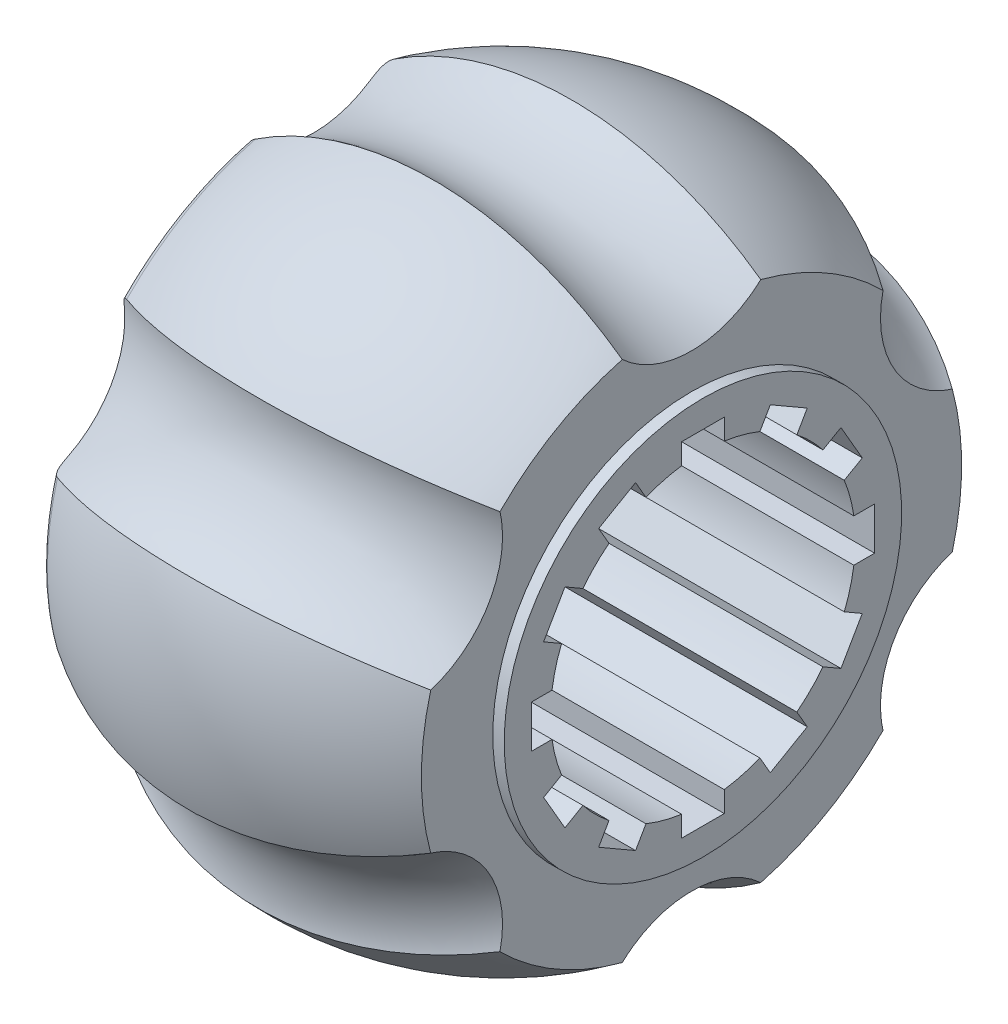
from build123d import *

# Parameters (mm, degrees)
FILLET1_R          = 2
SKETCH3_R          = 8.335
CIRPATTERN1_COUNT  = 6
CUT_EXTRUDE1_REACH = 69.845
SKETCH5_W          = 3.058833335
SKETCH5_H          = 3.5
CIRPATTERN2_COUNT  = 12


with BuildPart() as part:
    # Sketch1 → Revolve1 (revolve)
    with BuildSketch(Plane.XY):
        with BuildLine():
            Line((13.386210924, -10.675476076), (13.386210924, -4.817713103))
            ThreePointArc((13.386210924, -4.817713103), (-2.116785533, 0.057748096), (-17.613789076, -4.836728616))
            Line((-17.613789076, -4.836728616), (-17.613789076, -13.475476076))
            Line((-17.613789076, -13.475476076), (-16.613789076, -14.475476076))
            Line((-16.613789076, -14.475476076), (13.4271182, -14.475476076))
            Line((13.4271182, -14.475476076), (14.323961654, -14.475476076))
            Line((14.323961654, -14.475476076), (14.323961654, -10.675476076))
            Line((14.323961654, -10.675476076), (13.386210924, -10.675476076))
        make_face()
    revolve(axis=Axis((13.4271182, -26.975476076, 0), (-1, 0, 0)))

    # Fillet1
    fillet1_edges = [part.edges().sort_by_distance(p)[0] for p in [
        (-17.613789076, -49.114223536, 0),
    ]]
    fillet(fillet1_edges, radius=FILLET1_R)

    # Cut-Sweep2: sweep along a path in Sketch4
    with BuildLine(Plane.XY) as cut_sweep2_path:
        ThreePointArc((-17.613789076, -0.853454732), (2.484971781, 3.057963853), (20.501054004, -6.67240945))
    # Sketch3 → Cut-Sweep2 (sweep, cut)
    with BuildSketch(Plane.ZY.offset(17.613789076)):
        with Locations((0, 0.524523924)):
            Circle(SKETCH3_R)
    cut_sweep2 = sweep(path=cut_sweep2_path.line, mode=Mode.SUBTRACT)

    # CirPattern1: Cut-Sweep2 ×6 about axis
    cirpattern1_axis = Axis((-17.613789076, -26.975476076, 0), (1, 0, 0))
    for i in range(1, CIRPATTERN1_COUNT):
        add(cut_sweep2.rotate(cirpattern1_axis, i * 360 / CIRPATTERN1_COUNT), mode=Mode.SUBTRACT)

    # Sketch5 → Cut-Extrude1 (cut, up to next)
    with BuildSketch(Plane.ZY.offset(17.613789076), mode=Mode.PRIVATE) as cut_extrude1_sk1:
        with Locations((-12.55060814, -26.975476076)):
            Rectangle(SKETCH5_W, SKETCH5_H)
    cut_extrude1_tool1 = extrude(cut_extrude1_sk1.sketch, amount=-CUT_EXTRUDE1_REACH, mode=Mode.PRIVATE) & part.part
    cut_extrude1 = cut_extrude1_tool1.solids().sort_by_distance((-17.613789, -26.975476, -12.550608))[0]
    add(cut_extrude1, mode=Mode.SUBTRACT)

    # CirPattern2: Cut-Extrude1 ×12 about axis
    cirpattern2_axis = Axis((-17.613789076, -26.975476076, 0), (1, 0, 0))
    for i in range(1, CIRPATTERN2_COUNT):
        add(cut_extrude1.rotate(cirpattern2_axis, i * 360 / CIRPATTERN2_COUNT), mode=Mode.SUBTRACT)


solid = part.part
